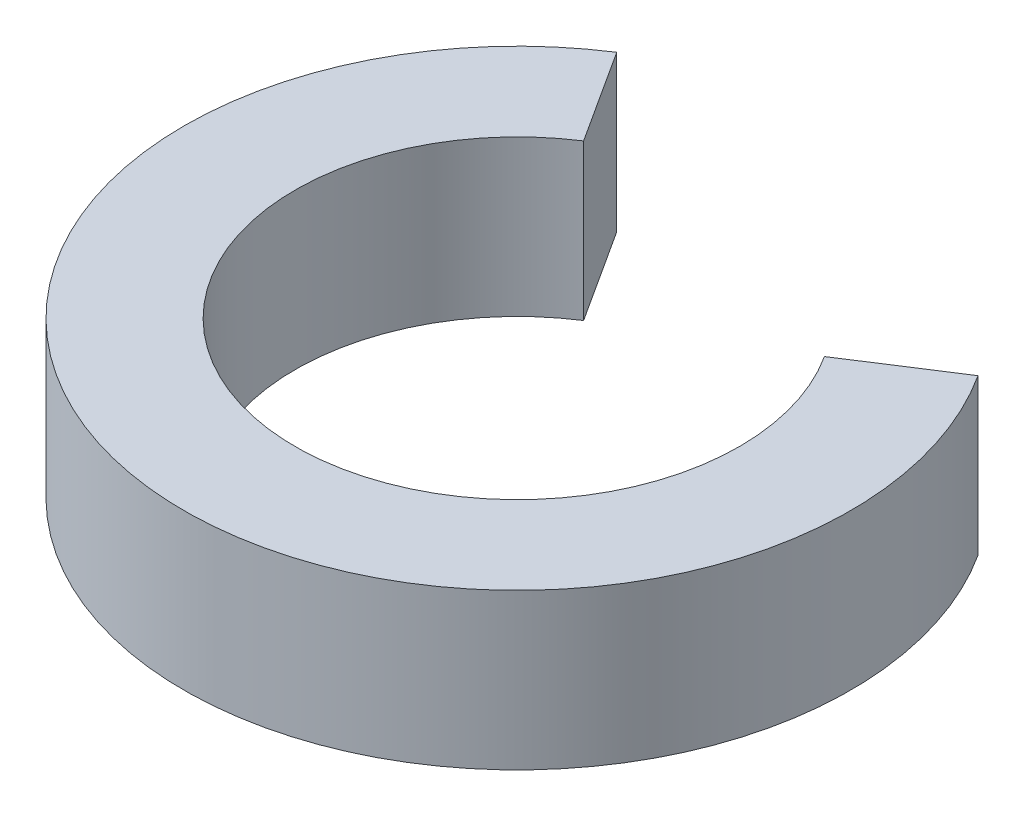
from build123d import *

# Parameters (mm, degrees)
EXTRUDE_1_DEPTH = 7


with BuildPart() as part:
    # Эскиз1 → Бобышка-Вытянуть1 (new body)
    with BuildSketch(Plane(origin=(0, 0, 0), x_dir=(1, 0, 0), z_dir=(0, 1, 0))):
        with BuildLine():
            Line((-5.419881538, 8.403861262), (-8.129822308, 12.605791893))
            ThreePointArc((-8.129822308, 12.605791893), (-3.164988446, -14.662293413), (12.605791893, 8.129822308))
            Line((12.605791893, 8.129822308), (8.403861262, 5.419881538))
            ThreePointArc((8.403861262, 5.419881538), (-2.109992297, -9.774862276), (-5.419881538, 8.403861262))
        make_face()
    extrude(amount=EXTRUDE_1_DEPTH)


solid = part.part
